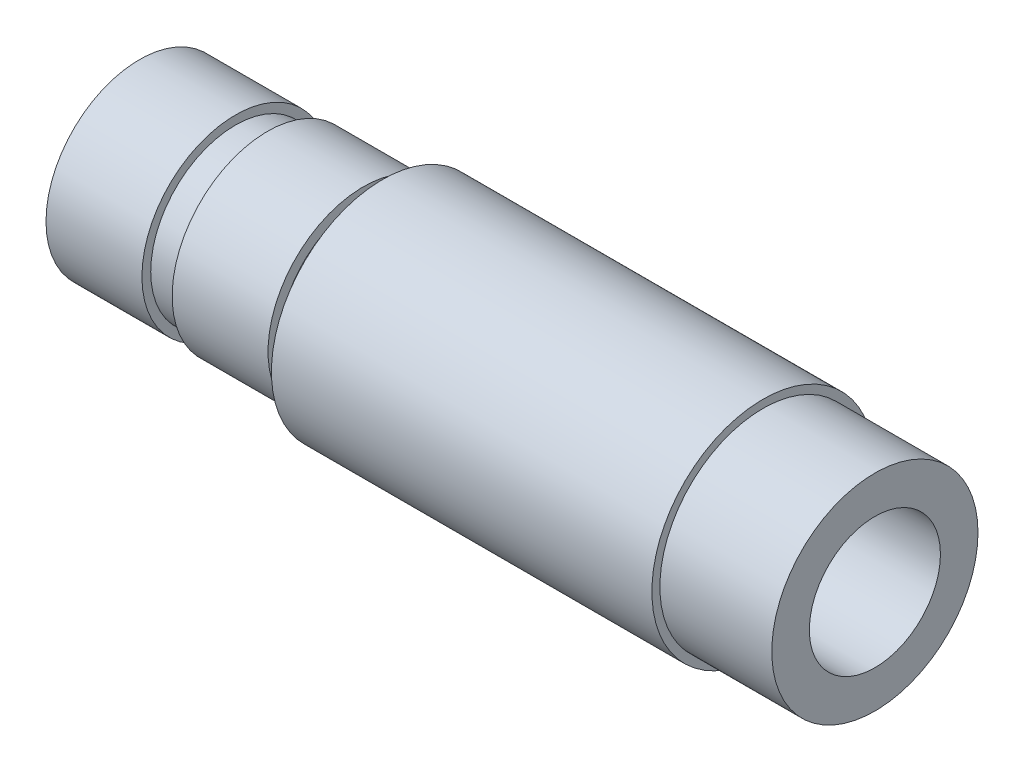
from build123d import *

# Parameters (mm, degrees)
TAP_DRILL_FOR_M5_TAP1_D     = 4.1
TAP_DRILL_FOR_M5_TAP1_DEPTH = 5.5
TAP_DRILL_FOR_M5_TAP1_TIP   = 1.231764269
SKETCH5_R                   = 1.75
CUT_EXTRUDE1_DEPTH          = 29.8


with BuildPart() as part:
    # Sketch2 → Revolve4 (revolve)
    with BuildSketch(Plane.XY):
        Polygon((292.362244726, 80.31885353), (304.262244726, 80.31885353), (304.262244726, 80.06885353), (307.762244726, 80.06885353), (307.762244726, 76.84385353), (284.762244726, 76.84385353), (284.762244726, 79.76885353), (287.762244726, 79.76885353), (287.762244726, 79.49385353), (288.762244726, 79.49385353), (288.762244726, 79.82385353), (291.762244726, 79.82385353), (291.762244726, 79.49385353), (292.362244726, 79.49385353), align=None)
    revolve(axis=Axis((307.762244726, 76.84385353, 0), (-1, 0, 0)))

    # Tap Drill for M5 Tap1
    with Locations(Plane(origin=(307.762244726, 0, 0), x_dir=(0, 0, -1), z_dir=(1, 0, 0))):
        with Locations((0, 76.84385353)):
            Hole(TAP_DRILL_FOR_M5_TAP1_D / 2, depth=TAP_DRILL_FOR_M5_TAP1_DEPTH)
            with Locations((0, 0, -(TAP_DRILL_FOR_M5_TAP1_DEPTH + TAP_DRILL_FOR_M5_TAP1_TIP / 2))):  # 118° drill point
                Cone(0, TAP_DRILL_FOR_M5_TAP1_D / 2, TAP_DRILL_FOR_M5_TAP1_TIP, mode=Mode.SUBTRACT)

    # Sketch5 → Cut-Extrude1 (cut)
    with BuildSketch(Plane.ZY.offset(-284.762244726)):
        with Locations((0, 76.84385353)):
            Circle(SKETCH5_R)
    extrude(amount=-CUT_EXTRUDE1_DEPTH, mode=Mode.SUBTRACT)


solid = part.part
